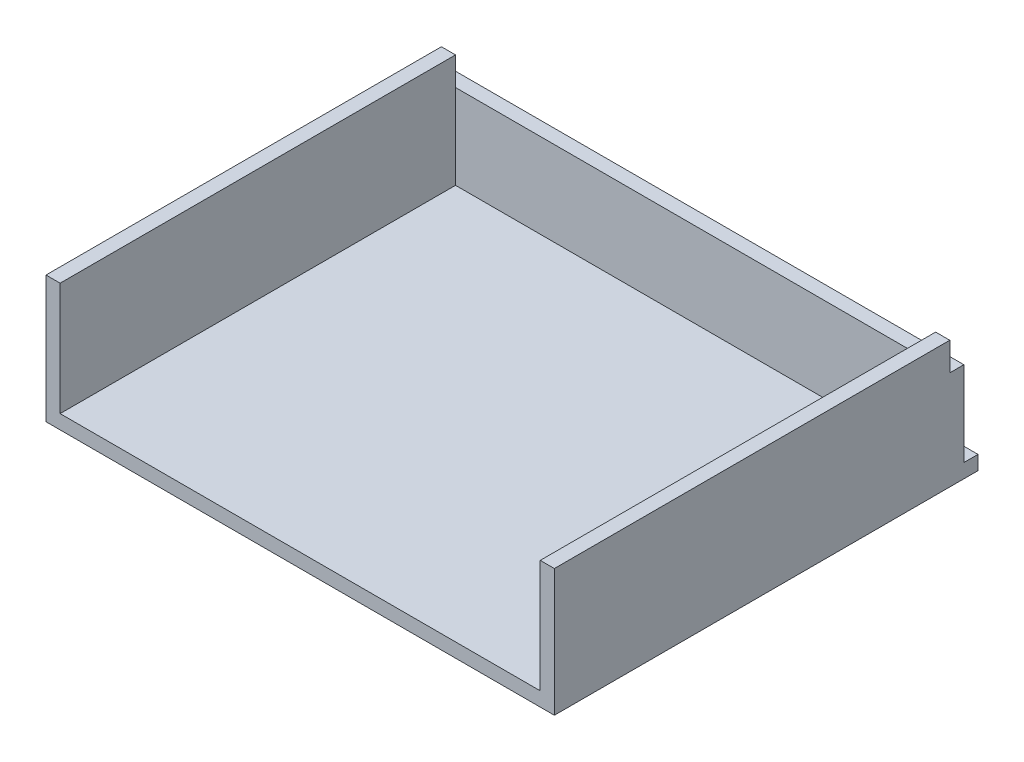
from build123d import *

# Parameters (mm, degrees)
SKETCH1_W           = 180
SKETCH1_H           = 150
BOSS_EXTRUDE1_DEPTH = 5
SKETCH5_W           = 5
SKETCH5_H           = 40
BOSS_EXTRUDE2_DEPTH = 140
SKETCH13_W          = 5
SKETCH13_H          = 30
BOSS_EXTRUDE9_DEPTH = 180


with BuildPart() as part:
    # Sketch1 → Boss-Extrude1 (new body)
    with BuildSketch(Plane(origin=(0, 0, 0), x_dir=(1, 0, 0), z_dir=(0, 1, 0))):
        with Locations((9.394856278, -24.757942511)):
            Rectangle(SKETCH1_W, SKETCH1_H)
    extrude(amount=BOSS_EXTRUDE1_DEPTH)

    # Sketch5 → Boss-Extrude2 (add)
    with BuildSketch(Plane.XY.offset(99.757942511)):
        with Locations((-78.105143722, 25)):
            Rectangle(SKETCH5_W, SKETCH5_H)
        with Locations((96.894856278, 25)):
            Rectangle(SKETCH5_W, SKETCH5_H)
    extrude(amount=-BOSS_EXTRUDE2_DEPTH)

    # Sketch13 → Boss-Extrude9 (add)
    with BuildSketch(Plane(origin=(99.394856278, 0, 0), x_dir=(0, 0, -1), z_dir=(1, 0, 0))):
        with Locations((42.742057489, 20)):
            Rectangle(SKETCH13_W, SKETCH13_H)
    extrude(amount=-BOSS_EXTRUDE9_DEPTH)


solid = part.part
